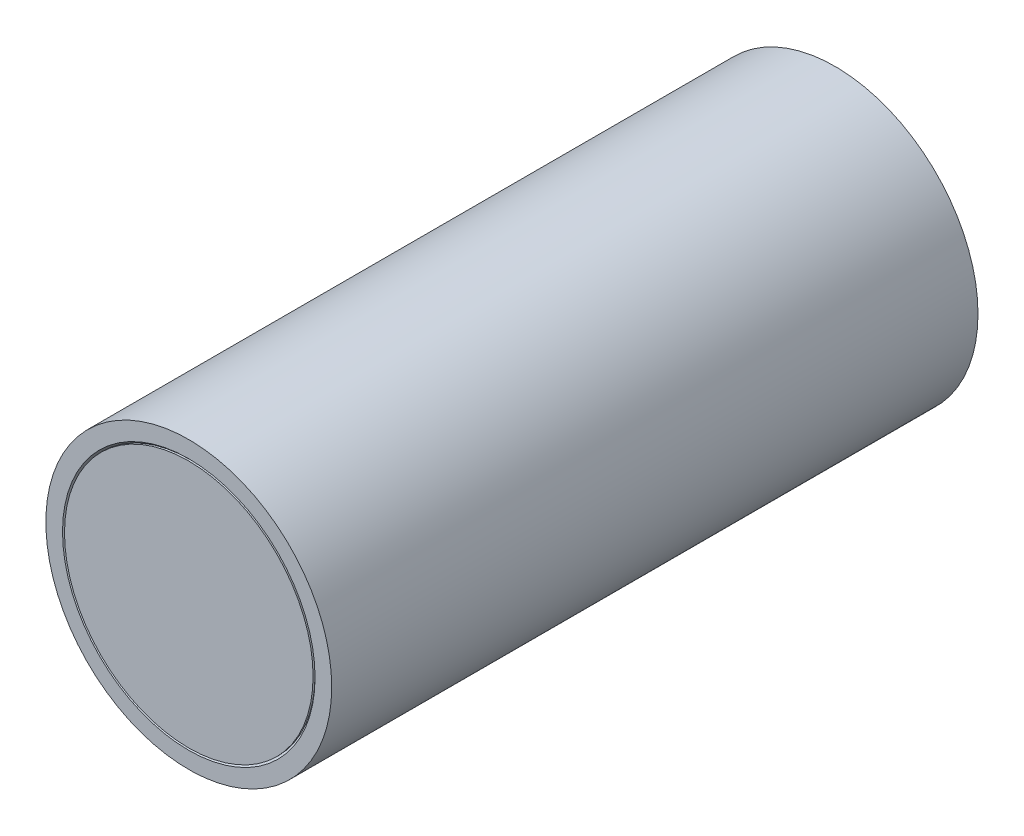
from build123d import *

# Parameters (mm, degrees)
SKETCH1_R           = 36.5125
SKETCH1_R_2         = 31.75
EXTRUDE1_DEPTH      = 165.1
CHAMFER1_SIZE       = 0.508
SKETCH1_2_R         = 31.75
BOSS_EXTRUDE1_DEPTH = 165.1


with BuildPart() as part:
    # Sketch1 → Extrude1 (new body)
    with BuildSketch(Plane.XY):
        Circle(SKETCH1_R)
        Circle(SKETCH1_R_2, mode=Mode.SUBTRACT)
    extrude(amount=EXTRUDE1_DEPTH)

    # Chamfer1
    chamfer1_edges = [part.edges().sort_by_distance(p)[0] for p in [
        (-31.75, 0, 165.1),
        (-31.75, 0, 0),
    ]]
    chamfer(chamfer1_edges, length=CHAMFER1_SIZE)


with BuildPart() as body_2:
    # Sketch1_2 → Boss-Extrude1 (new body)
    with BuildSketch(Plane.XY):
        Circle(SKETCH1_2_R)
    extrude(amount=BOSS_EXTRUDE1_DEPTH)


solid = Compound([part.part, body_2.part])
